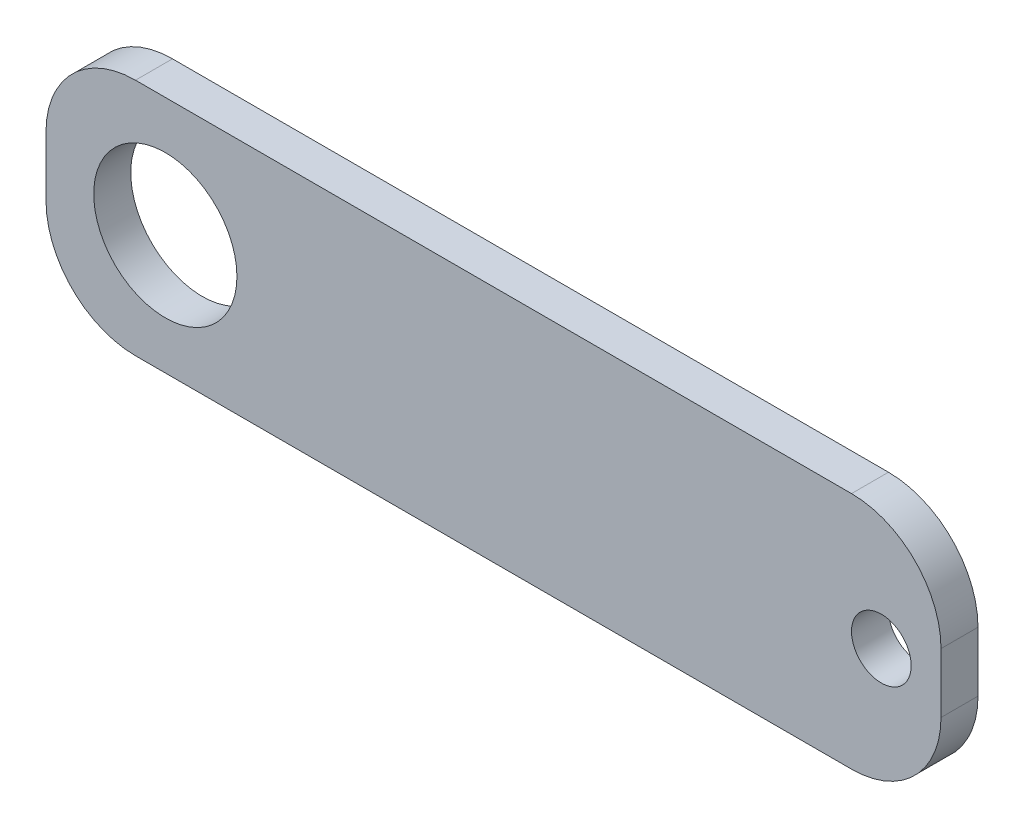
from build123d import *

# Parameters (mm, degrees)
SKETCH1_W           = 75
SKETCH1_H           = 20
SKETCH1_R           = 2.5
SKETCH1_R_2         = 6
BOSS_EXTRUDE1_DEPTH = 3.1
FILLET1_R           = 7.5


with BuildPart() as part:
    # Sketch1 → Boss-Extrude1 (new body)
    with BuildSketch(Plane.XY):
        with Locations((9.88062329, 0)):
            Rectangle(SKETCH1_W, SKETCH1_H)
        with Locations((42.38062329, 0)):
            Circle(SKETCH1_R, mode=Mode.SUBTRACT)
        with Locations((-17.61937671, 0)):
            Circle(SKETCH1_R_2, mode=Mode.SUBTRACT)
    extrude(amount=BOSS_EXTRUDE1_DEPTH)

    # Fillet1
    fillet1_edges = [part.edges().sort_by_distance(p)[0] for p in [
        (-27.61937671, 10, 1.55),
        (47.38062329, 10, 1.55),
        (47.38062329, -10, 1.55),
        (-27.61937671, -10, 1.55),
    ]]
    fillet(fillet1_edges, radius=FILLET1_R)


solid = part.part
